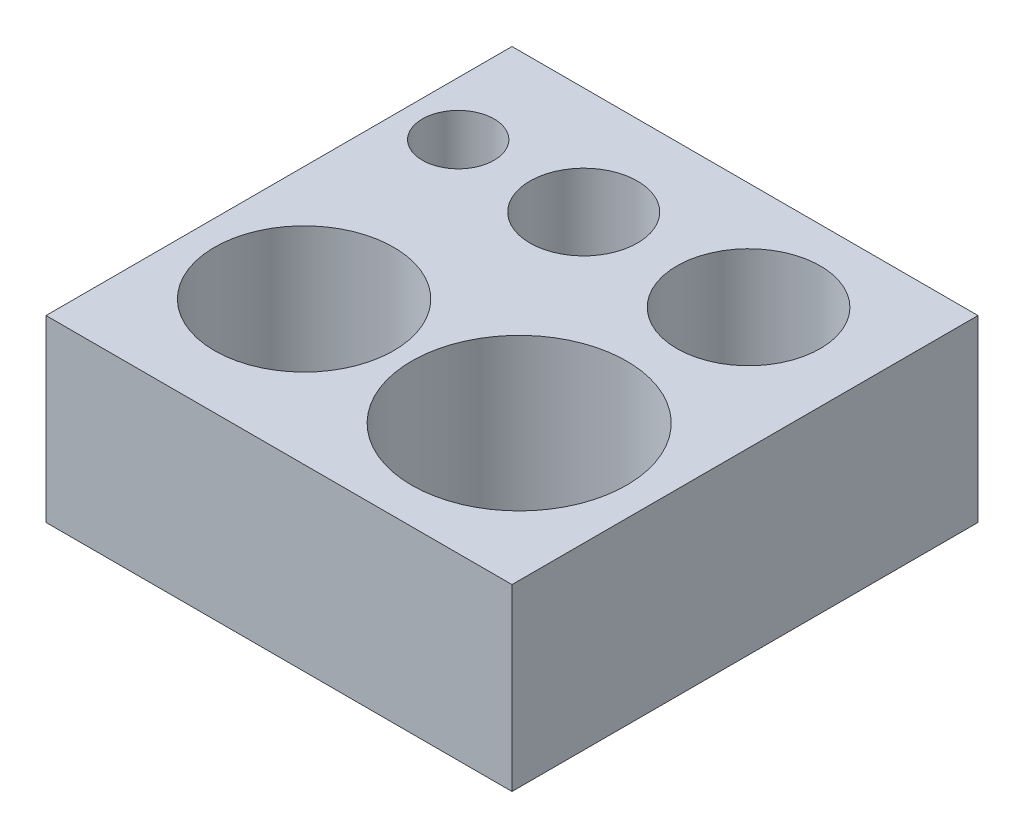
from build123d import *

# Parameters (mm, degrees)
SKETCH1_W           = 13
SKETCH1_H           = 13
SKETCH1_R           = 1
SKETCH1_R_2         = 1.5
SKETCH1_R_3         = 2
SKETCH1_R_4         = 2.5
SKETCH1_R_5         = 3
BOSS_EXTRUDE1_DEPTH = 5


with BuildPart() as part:
    # Sketch1 → Boss-Extrude1 (new body)
    with BuildSketch(Plane(origin=(0, 0, 0), x_dir=(1, 0, 0), z_dir=(0, 1, 0))):
        with Locations((6.5, 6.5)):
            Rectangle(SKETCH1_W, SKETCH1_H)
        with Locations((1.5, 10)):
            Circle(SKETCH1_R, mode=Mode.SUBTRACT)
        with Locations((5, 10)):
            Circle(SKETCH1_R_2, mode=Mode.SUBTRACT)
        with Locations((9.6, 10)):
            Circle(SKETCH1_R_3, mode=Mode.SUBTRACT)
        with Locations((3.2, 4)):
            Circle(SKETCH1_R_4, mode=Mode.SUBTRACT)
        with Locations((9.2, 4)):
            Circle(SKETCH1_R_5, mode=Mode.SUBTRACT)
    extrude(amount=BOSS_EXTRUDE1_DEPTH)


solid = part.part
